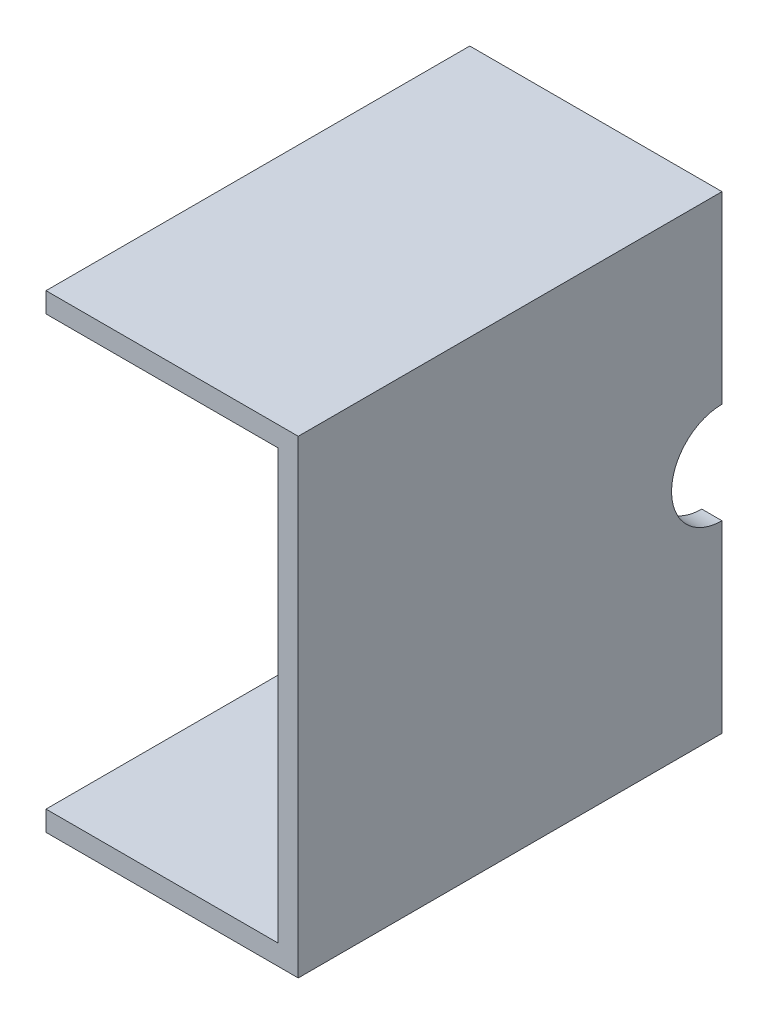
from build123d import *

# Parameters (mm, degrees)
SKETCH1_W           = 42
SKETCH1_H           = 46.5
BOSS_EXTRUDE1_DEPTH = 2
SKETCH2_W           = 42
SKETCH2_H           = 2
BOSS_EXTRUDE2_DEPTH = 23
CUT_EXTRUDE1_DEPTH  = 23
BOSS_EXTRUDE3_DEPTH = 23


with BuildPart() as part:
    # Sketch1 → Boss-Extrude1 (new body)
    with BuildSketch(Plane(origin=(0, 0, 0), x_dir=(0, 0, -1), z_dir=(1, 0, 0))):
        Rectangle(SKETCH1_W, SKETCH1_H)
    extrude(amount=BOSS_EXTRUDE1_DEPTH)

    # Sketch2 → Boss-Extrude2 (add)
    with BuildSketch(Plane.ZY):
        with Locations((0, -22.25)):
            Rectangle(SKETCH2_W, SKETCH2_H)
    extrude(amount=BOSS_EXTRUDE2_DEPTH)

    # Sketch3 → Cut-Extrude1 (cut)
    with BuildSketch(Plane(origin=(2, 0, 0), x_dir=(0, 0, -1), z_dir=(1, 0, 0))):
        with BuildLine():
            Line((21, -5), (21, 5))
            ThreePointArc((21, 5), (16, 0), (21, -5))
        make_face()
    extrude(amount=-CUT_EXTRUDE1_DEPTH, mode=Mode.SUBTRACT)

    # Sketch4 → Boss-Extrude3 (add)
    with BuildSketch(Plane.ZY):
        Polygon((21, 23.25), (-21, 23.25), (-21, 21.25), (-3.2, 21.25), (-4.5, 19.95), (4.5, 19.95), (3.2, 21.25), (21, 21.25), align=None)
    extrude(amount=BOSS_EXTRUDE3_DEPTH)


solid = part.part
